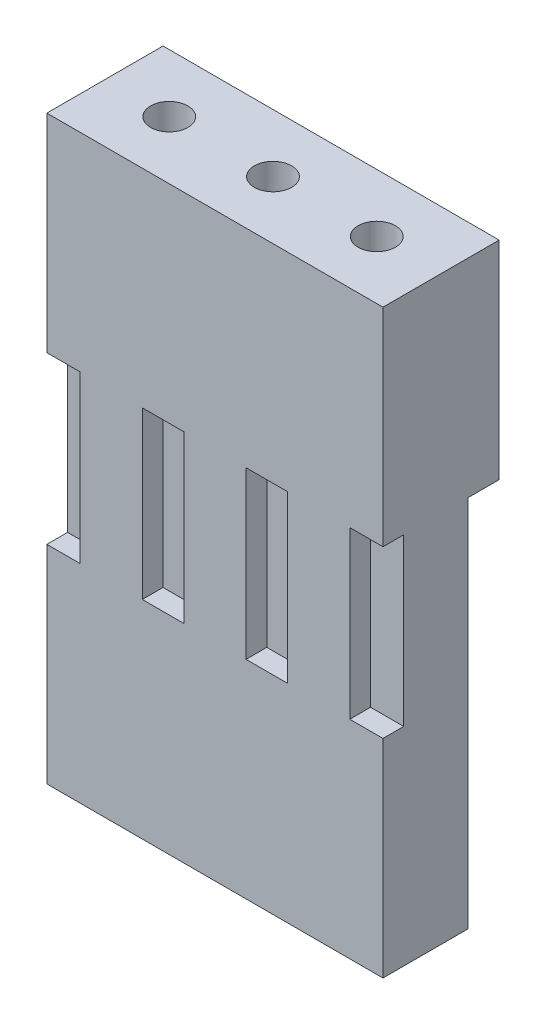
from build123d import *

# Parameters (mm, degrees)
SKETCH3_W           = 8.1
SKETCH3_H           = 2.8
SKETCH3_R           = 0.45
BOSS_EXTRUDE1_DEPTH = 5
SKETCH4_R           = 0.45
BOSS_EXTRUDE4_DEPTH = 9
SKETCH7_W           = 1
SKETCH7_H           = 4
CUT_EXTRUDE2_DEPTH  = 0.5


with BuildPart() as part:
    # Sketch3 → Boss-Extrude1 (new body)
    with BuildSketch(Plane(origin=(0, 0, 0), x_dir=(1, 0, 0), z_dir=(0, 1, 0))):
        Rectangle(SKETCH3_W, SKETCH3_H)
        with Locations((2.5, 0)):
            Circle(SKETCH3_R, mode=Mode.SUBTRACT)
        with Locations((-2.5, 0)):
            Circle(SKETCH3_R, mode=Mode.SUBTRACT)
        Circle(SKETCH3_R, mode=Mode.SUBTRACT)
    extrude(amount=-BOSS_EXTRUDE1_DEPTH)

    # Sketch4 → Boss-Extrude4 (add)
    with BuildSketch(Plane.XZ.offset(5)):
        Polygon((4.05, -0.65), (3.3, -1.4), (-3.3, -1.4), (-4.05, -0.65), (-4.05, 1.4), (4.05, 1.4), align=None)
        with Locations((2.5, 0)):
            Circle(SKETCH4_R, mode=Mode.SUBTRACT)
        Circle(SKETCH4_R, mode=Mode.SUBTRACT)
        with Locations((-2.5, 0)):
            Circle(SKETCH4_R, mode=Mode.SUBTRACT)
    extrude(amount=BOSS_EXTRUDE4_DEPTH)

    # Sketch7 → Cut-Extrude2 (cut)
    with BuildSketch(Plane.XY.offset(1.4)):
        with Locations((-3.75, -7)):
            Rectangle(SKETCH7_W, SKETCH7_H)
        with Locations((3.75, -7)):
            Rectangle(SKETCH7_W, SKETCH7_H)
        with Locations((-1.25, -7)):
            Rectangle(SKETCH7_W, SKETCH7_H)
        with Locations((1.25, -7)):
            Rectangle(SKETCH7_W, SKETCH7_H)
    extrude(amount=-CUT_EXTRUDE2_DEPTH, mode=Mode.SUBTRACT)


solid = part.part
